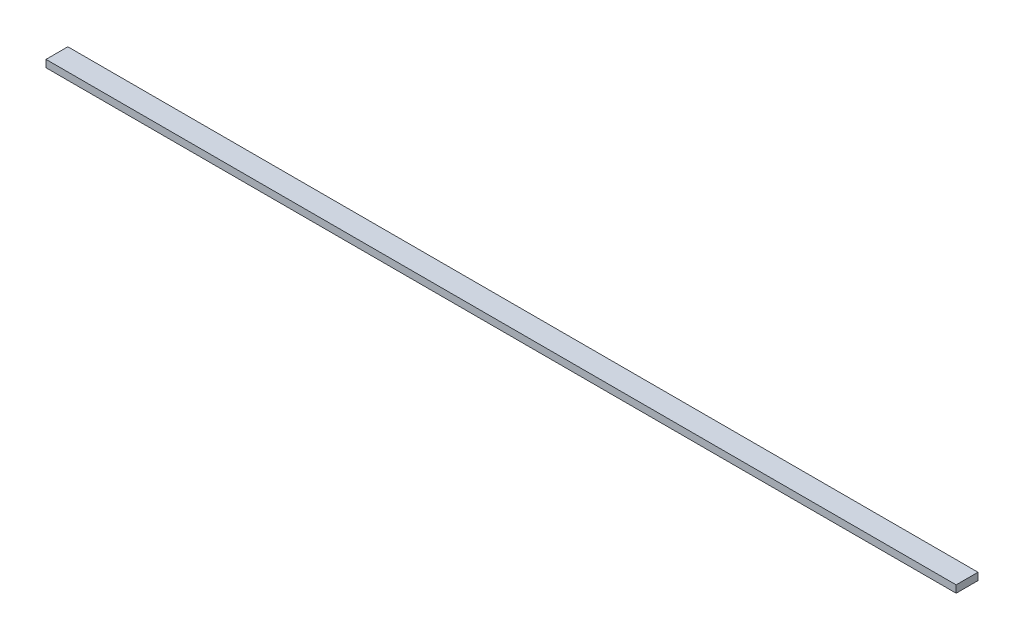
from build123d import *

# Parameters (mm, degrees)
SKETCH1_W           = 1250
SKETCH1_H           = 30
BOSS_EXTRUDE1_DEPTH = 10


with BuildPart() as part:
    # Sketch1 → Boss-Extrude1 (new body)
    with BuildSketch(Plane(origin=(0, 0, 0), x_dir=(1, 0, 0), z_dir=(0, 1, 0))):
        Rectangle(SKETCH1_W, SKETCH1_H)
    extrude(amount=BOSS_EXTRUDE1_DEPTH)


solid = part.part
